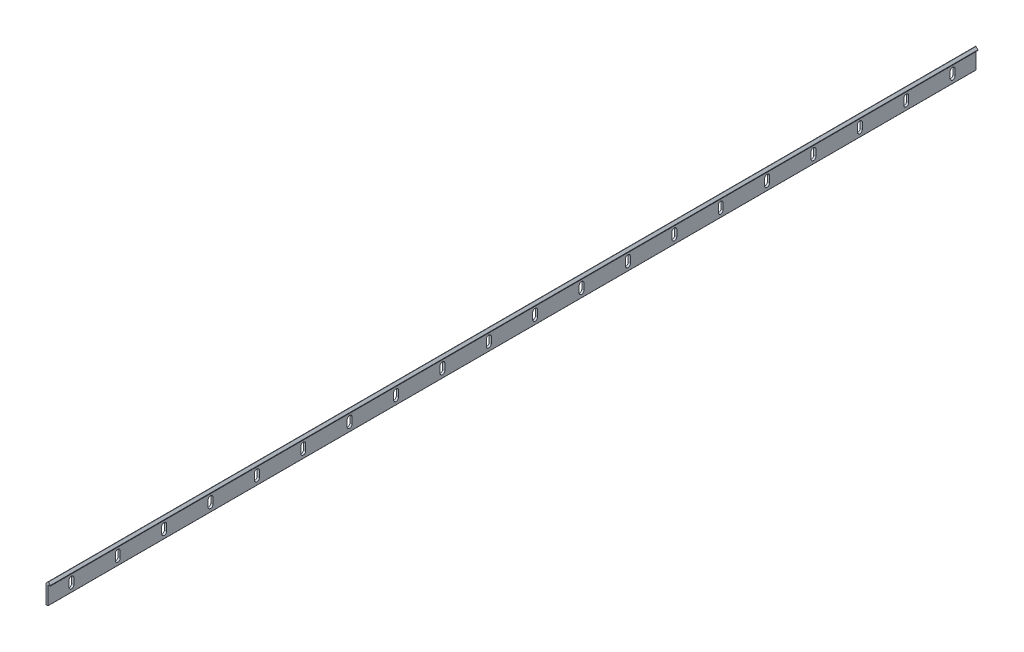
from build123d import *

# Parameters (mm, degrees)
BOSS_EXTRUDE1_DEPTH = 1000
CUT_EXTRUDE1_DEPTH  = 3.375
LPATTERN1_COUNT     = 20
LPATTERN1_PITCH     = 50


with BuildPart() as part:
    # Sketch1 → Boss-Extrude1 (new body)
    with BuildSketch(Plane.XY):
        with BuildLine():
            Line((0, 0.3), (0, 20.125))
            ThreePointArc((0, 20.125), (0.02283614, 20.23980503), (0.087867966, 20.337132034))
            Line((0.087867966, 20.337132034), (2.162867966, 22.412132034))
            ThreePointArc((2.162867966, 22.412132034), (2.375, 22.5), (2.587132034, 22.412132034))
            Line((2.587132034, 22.412132034), (4.662132034, 20.337132034))
            ThreePointArc((4.662132034, 20.337132034), (4.72716386, 20.23980503), (4.75, 20.125))
            Line((4.75, 20.125), (4.75, 19.85))
            ThreePointArc((4.75, 19.85), (4.662132034, 19.637867966), (4.45, 19.55))
            Line((4.45, 19.55), (2.375, 19.55))
            Line((2.375, 19.55), (2.375, 0.3))
            ThreePointArc((2.375, 0.3), (2.287132034, 0.087867966), (2.075, 0))
            Line((2.075, 0), (0.3, 0))
            ThreePointArc((0.3, 0), (0.087867966, 0.087867966), (0, 0.3))
        make_face()
    extrude(amount=BOSS_EXTRUDE1_DEPTH)

    # Sketch2 → Cut-Extrude1 (cut, through all)
    with BuildSketch(Plane(origin=(2.375, 0, 0), x_dir=(0, 0, -1), z_dir=(1, 0, 0))):
        with BuildLine():
            Line((-22.35, 12.7), (-22.35, 6))
            ThreePointArc((-22.35, 6), (-25, 3.35), (-27.65, 6))
            Line((-27.65, 6), (-27.65, 12.7))
            ThreePointArc((-27.65, 12.7), (-25, 15.35), (-22.35, 12.7))
        make_face()
    cut_extrude1 = extrude(amount=-CUT_EXTRUDE1_DEPTH, mode=Mode.SUBTRACT)

    # LPattern1: Cut-Extrude1 ×20
    with Locations(*[(0, 0, i * LPATTERN1_PITCH) for i in range(1, LPATTERN1_COUNT)]):
        add(cut_extrude1, mode=Mode.SUBTRACT)


solid = part.part
